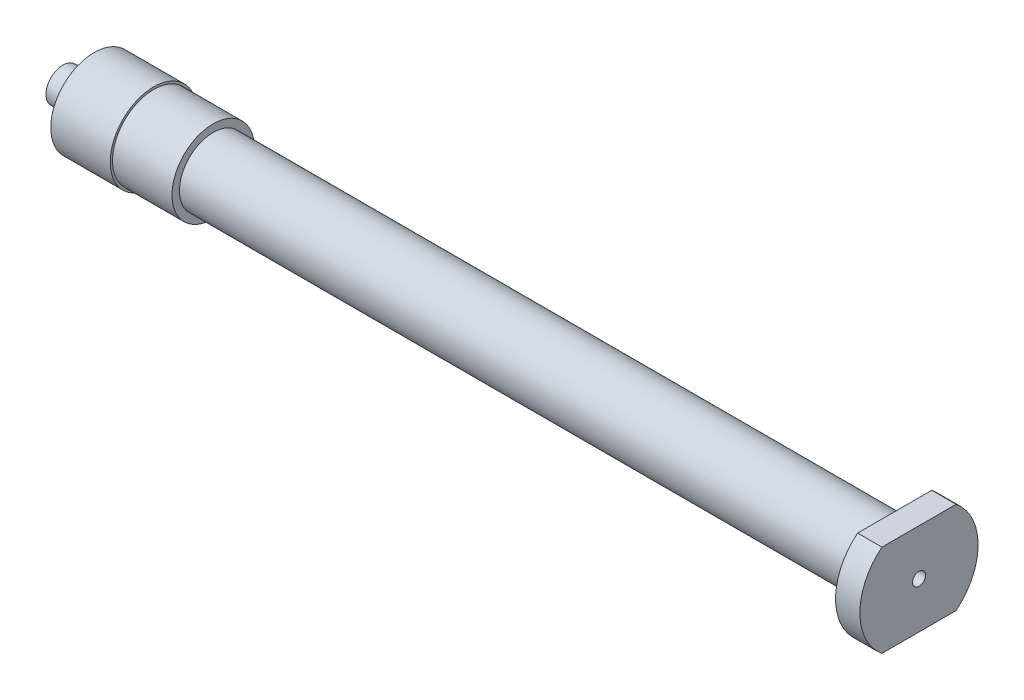
from build123d import *

# Parameters (mm, degrees)
SKETCH2_W          = 19
SKETCH2_H          = 14.6
SKETCH2_W_2        = 15
SKETCH2_H_2        = 10.6
CUT_EXTRUDE1_DEPTH = 2.8


with BuildPart() as part:
    # Sketch1 → Revolve1 (revolve)
    with BuildSketch(Plane(origin=(0, 0, 0), x_dir=(1, 0, 0), z_dir=(0, 1, 0))):
        Polygon((-49.285, 0.6), (-49.285, 1.95), (-42.185, 2.322095233), (-42.185, 4.1), (-45.685, 4.1), (-45.685, 5), (-38.835, 5), (-38.835, 4.74), (-31.985, 4.74), (-31.985, 3.885), (46.485, 3.885), (46.485, 6.805), (49.285, 6.805), (49.285, 0.75), (-31.985, 0.75), (-31.985, 0.6), align=None)
    revolve(axis=Axis((49.285, 0, 0), (-1, 0, 0)))

    # Sketch2 → Cut-Extrude1 (cut)
    with BuildSketch(Plane(origin=(49.285, 0, 0), x_dir=(0, 0, -1), z_dir=(1, 0, 0))):
        Rectangle(SKETCH2_W, SKETCH2_H)
        Rectangle(SKETCH2_W_2, SKETCH2_H_2, mode=Mode.SUBTRACT)
    extrude(amount=-CUT_EXTRUDE1_DEPTH, mode=Mode.SUBTRACT)


solid = part.part
